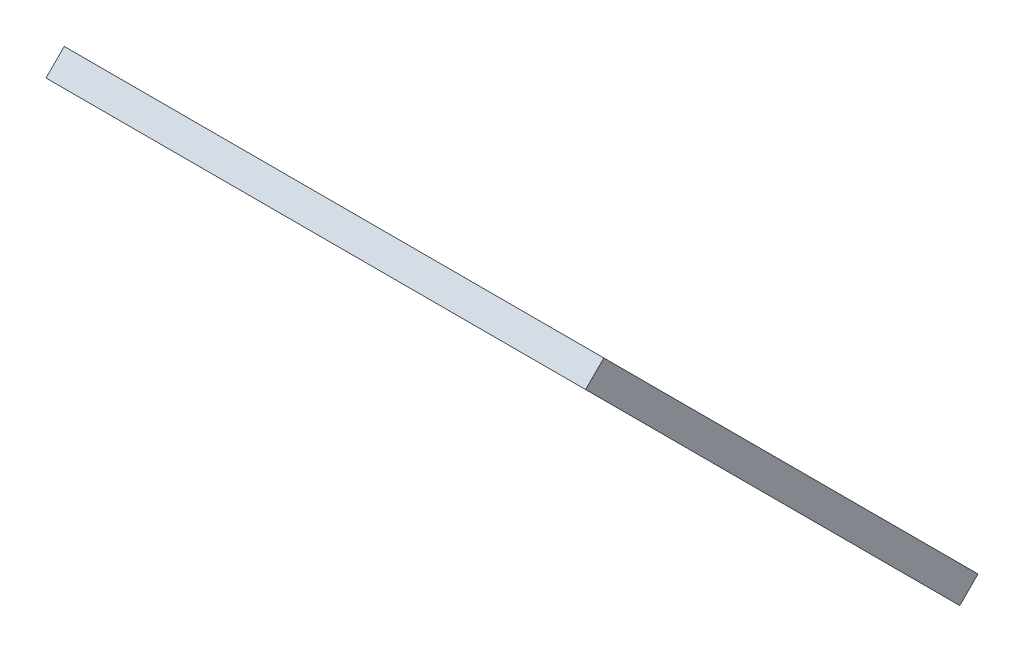
from build123d import *

# Parameters (mm, degrees)
BOSS_EXTRUDE1_DEPTH = 1.5


with BuildPart() as part:
    # Sketch1 → Boss-Extrude1 (new body, symmetric)
    with BuildSketch(Plane(origin=(0, -80.401490288, 80.401490288), x_dir=(-1, 0, 0), z_dir=(0, -0.707106781, 0.707106781))):
        Polygon((-111.164878, 111.164878), (-111.164878, 49.638102576), (-48.412903325, 49.638102576), (-4.906903198, 111.164878), align=None)
    extrude(amount=BOSS_EXTRUDE1_DEPTH, both=True)


solid = part.part
